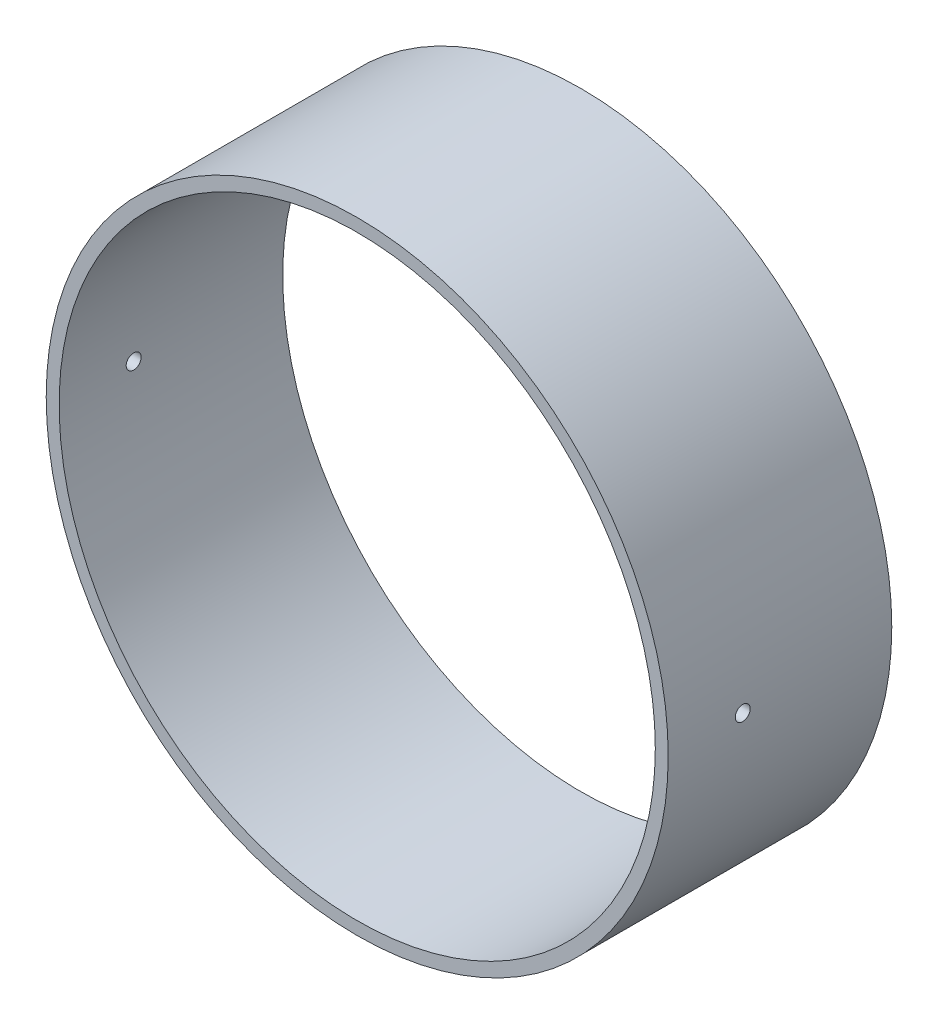
from build123d import *

# Parameters (mm, degrees)
SKETCH1_R           = 39.75
SKETCH1_R_2         = 38.1
BOSS_EXTRUDE1_DEPTH = 28.575
SKETCH2_R           = 0.9525
CUT_EXTRUDE1_DEPTH  = 80.5


with BuildPart() as part:
    # Sketch1 → Boss-Extrude1 (new body)
    with BuildSketch(Plane.XY):
        Circle(SKETCH1_R)
        Circle(SKETCH1_R_2, mode=Mode.SUBTRACT)
    extrude(amount=BOSS_EXTRUDE1_DEPTH)

    # Sketch2 → Cut-Extrude1 (cut, through all)
    with BuildSketch(Plane.ZY.offset(39.75)):
        with Locations((19.05, 0)):
            Circle(SKETCH2_R)
    extrude(amount=-CUT_EXTRUDE1_DEPTH, mode=Mode.SUBTRACT)


solid = part.part
